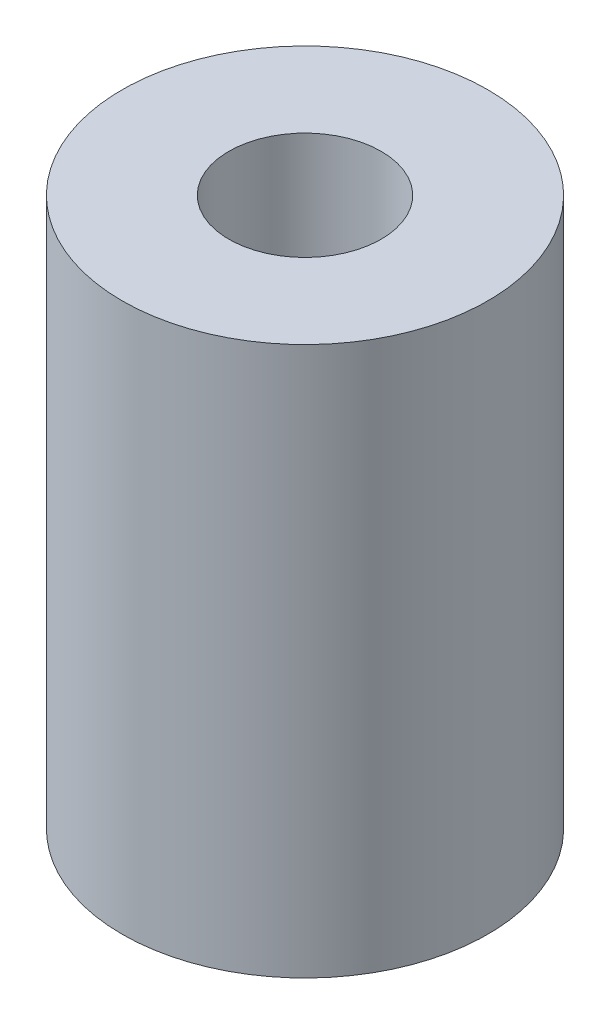
from build123d import *

# Parameters (mm, degrees)
SKETCH1_W = 3.5
SKETCH1_H = 18


with BuildPart() as part:
    # Sketch1 → Revolve1 (revolve)
    with BuildSketch(Plane.XY):
        with Locations((4.25, 9)):
            Rectangle(SKETCH1_W, SKETCH1_H)
    revolve(axis=Axis((0, 0, 0), (0, 1, 0)))


solid = part.part
